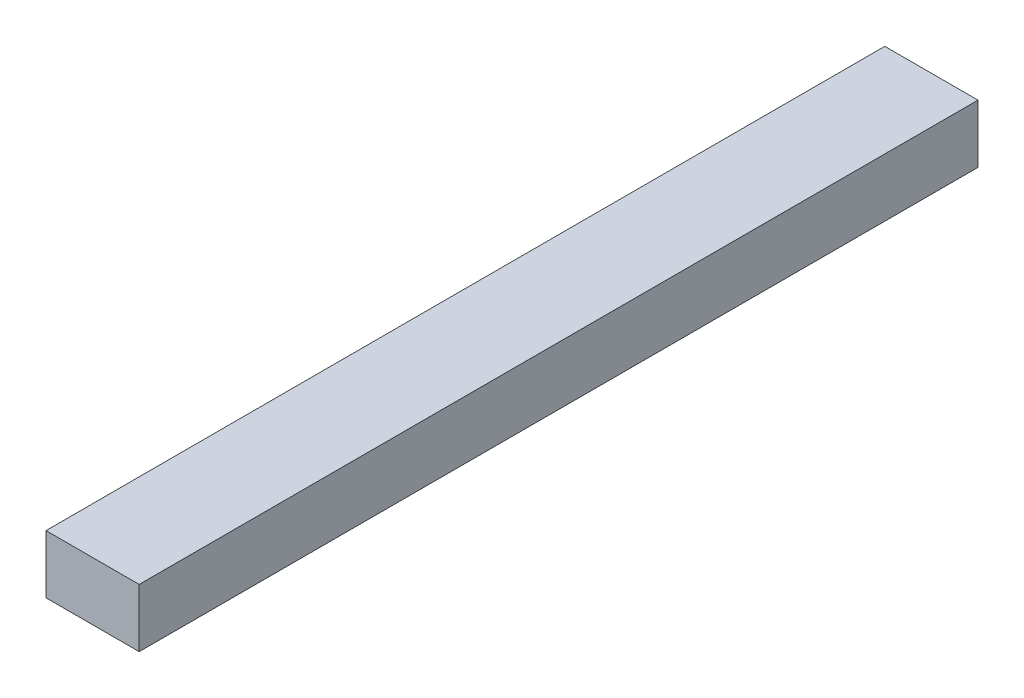
from build123d import *

# Parameters (mm, degrees)
SKETCH1_W                   = 25.4
SKETCH1_H                   = 15.875
BOSS_EXTRUDE1_DEPTH         = 114.3
F_1_2_13_TAPPED_HOLE1_D     = 10.71626
F_1_2_13_TAPPED_HOLE1_DEPTH = 31.242


with BuildPart() as part:
    # Sketch1 → Boss-Extrude1 (new body, symmetric)
    with BuildSketch(Plane.XY):
        Rectangle(SKETCH1_W, SKETCH1_H)
    extrude(amount=BOSS_EXTRUDE1_DEPTH, both=True)

    # 1/2-13 Tapped Hole1
    with Locations(Plane(origin=(0, 0, -114.3), x_dir=(-1, 0, 0), z_dir=(0, 0, -1))):
        with Locations((0, 0)):
            Hole(F_1_2_13_TAPPED_HOLE1_D / 2, depth=F_1_2_13_TAPPED_HOLE1_DEPTH)


solid = part.part
